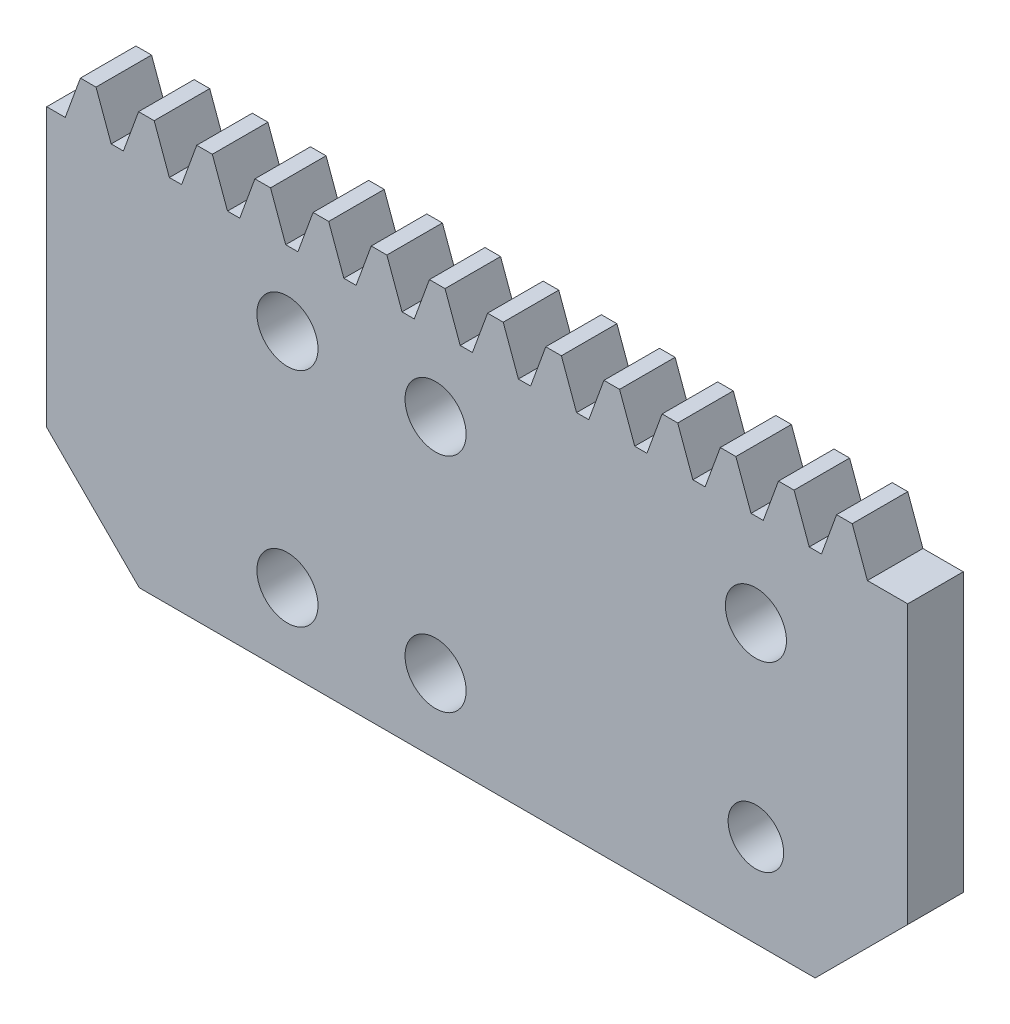
from build123d import *

# Parameters (mm, degrees)
SKETCH_1_W             = 46.5
SKETCH_1_H             = 20
EXTRUDE_1_DEPTH        = 3
EXTRUDE_2_DEPTH        = 3
PATTERN_LINEAR_1_COUNT = 14
PATTERN_LINEAR_1_PITCH = 3.141592654
SKETCH_3_R             = 1.65
CUT_EXTRUDE_1_DEPTH    = 3
SKETCH_4_R             = 1.65
SKETCH_4_R_2           = 1.5
CUT_EXTRUDE_2_DEPTH    = 10
CHAMFER_1_SIZE         = 5


with BuildPart() as part:
    # 草圖1 → 填料-伸長1 (new body)
    with BuildSketch(Plane.XY):
        Rectangle(SKETCH_1_W, SKETCH_1_H)
    extrude(amount=EXTRUDE_1_DEPTH)

    # 草圖2 → 填料-伸長2 (add)
    with BuildSketch(Plane.XY.offset(3)):
        Polygon((-22.25, 10), (-21.431066973, 12.25), (-20.588211115, 12.25), (-19.769278088, 10), align=None)
    extrude_2 = extrude(amount=-EXTRUDE_2_DEPTH)

    # 直線複製排列1: 填料-伸長2 ×14
    with Locations(*[(i * PATTERN_LINEAR_1_PITCH, 0, 0) for i in range(1, PATTERN_LINEAR_1_COUNT)]):
        add(extrude_2)

    # 草圖3 → 除料-伸長1 (cut)
    with BuildSketch(Plane.XY.offset(3)):
        with Locations((-10.25, 6)):
            Circle(SKETCH_3_R)
        with Locations((-2.25, 6)):
            Circle(SKETCH_3_R)
        with Locations((-2.25, -6)):
            Circle(SKETCH_3_R)
        with Locations((-10.25, -6)):
            Circle(SKETCH_3_R)
    extrude(amount=-CUT_EXTRUDE_1_DEPTH, mode=Mode.SUBTRACT)

    # 草圖4 → 除料-伸長2 (cut)
    with BuildSketch(Plane.XY.offset(3)):
        with Locations((15.05, 5)):
            Circle(SKETCH_4_R)
        with Locations((15.05, -5)):
            Circle(SKETCH_4_R_2)
    extrude(amount=-CUT_EXTRUDE_2_DEPTH, mode=Mode.SUBTRACT)

    # 導角1
    chamfer_1_edges = [part.edges().sort_by_distance(p)[0] for p in [
        (23.25, -10, 1.5),
        (-23.25, -10, 1.5),
    ]]
    chamfer(chamfer_1_edges, length=CHAMFER_1_SIZE)


solid = part.part
